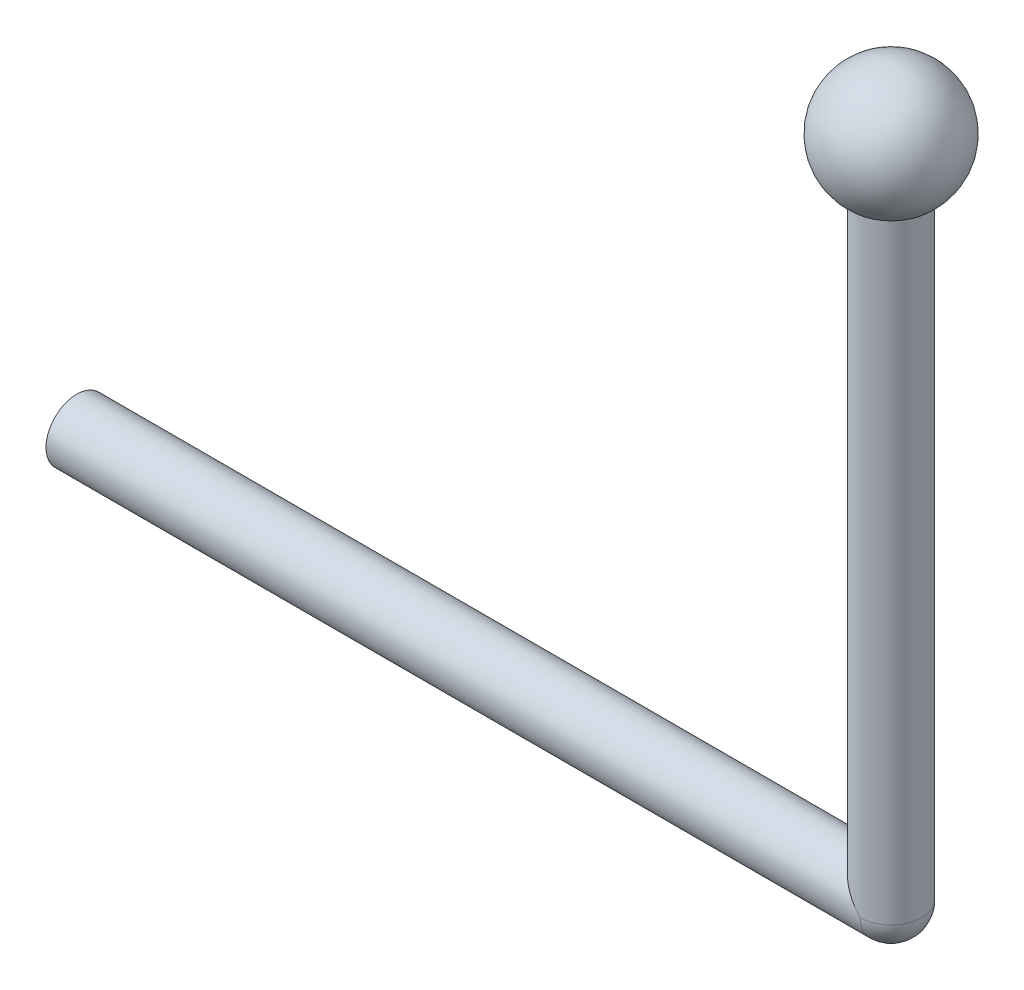
from build123d import *


with BuildPart() as part:
    # 草图1 → 旋转3 (revolve)
    with BuildSketch(Plane.XY):
        with BuildLine():
            Line((-2, 0), (0, 0))
            Line((0, 0), (0, 4))
            ThreePointArc((0, 4), (-3.863703305, 1.03527618), (-2, -3.464101615))
            Line((-2, -3.464101615), (-2, 0))
        make_face()
        with BuildLine():
            Line((0, -4), (0, 0))
            Line((0, 0), (-2, 0))
            Line((-2, 0), (-2, -3.464101615))
            ThreePointArc((-2, -3.464101615), (-1.03527618, -3.863703305), (0, -4))
        make_face()
    revolve(axis=Axis((0, -4, 0), (0, -1, 0)))

    # 草图3 → 旋转4 (revolve)
    with BuildSketch(Plane.XY):
        with BuildLine():
            Line((0, -43), (0, -2))
            ThreePointArc((0, -2), (-1.414213562, -1.414213562), (-2, 0))
            Line((-2, 0), (-2, -2))
            Line((-2, -2), (-2, -43))
            Line((-2, -43), (0, -43))
        make_face()
    revolve(axis=Axis((0, -2, 0), (0, -1, 0)))

    # 草图4 → 旋转6 (revolve)
    with BuildSketch(Plane.XZ.offset(43)):
        with BuildLine():
            Line((-52.778814048, 0), (-4, 0))
            ThreePointArc((-4, 0), (-3.863703305, 1.03527618), (-3.464101615, 2))
            Line((-3.464101615, 2), (-52.778814048, 2))
            Line((-52.778814048, 2), (-52.778814048, 0))
        make_face()
        with BuildLine():
            Line((-4, 0), (-2, 0))
            ThreePointArc((-2, 0), (-1.414213562, 1.414213562), (0, 2))
            Line((0, 2), (-0.493950763, 2))
            Line((-0.493950763, 2), (-3.464101615, 2))
            ThreePointArc((-3.464101615, 2), (-3.863703305, 1.03527618), (-4, 0))
        make_face()
        with BuildLine():
            Line((0, 2), (0, 0))
            Line((0, 0), (2, 0))
            ThreePointArc((2, 0), (1.414213562, 1.414213562), (0, 2))
        make_face()
        with BuildLine():
            Line((-2, 0), (-0.493950763, 0))
            Line((-0.493950763, 0), (0, 0))
            Line((0, 0), (0, 2))
            ThreePointArc((0, 2), (-1.414213562, 1.414213562), (-2, 0))
        make_face()
    revolve(axis=Axis((-0.493950763, -43, 0), (-1, 0, 0)))


solid = part.part
